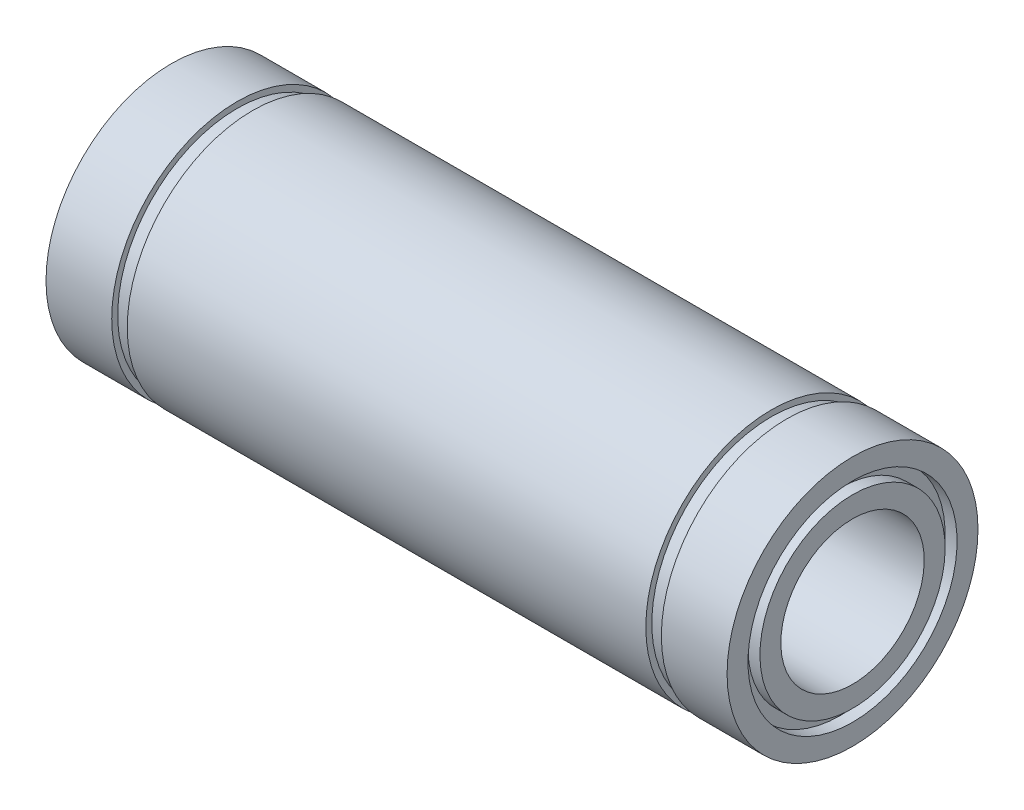
from build123d import *


with BuildPart() as part:
    # Esboço1 → Revolução1 (revolve)
    with BuildSketch(Plane.XY):
        Polygon((-28.5, 10.5), (-23, 10.5), (-23, 10), (-21.7, 10), (-21.7, 10.5), (21.7, 10.5), (21.7, 10), (23, 10), (23, 10.5), (28.5, 10.5), (28.5, 8.75), (27.5, 8.75), (27.5, 7.75), (28.5, 7.75), (28.5, 6), (-28.5, 6), (-28.5, 7.75), (-27.5, 7.75), (-27.5, 8.75), (-28.5, 8.75), align=None)
    revolve(axis=Axis((0, 0, 0), (-1, 0, 0)))


solid = part.part
